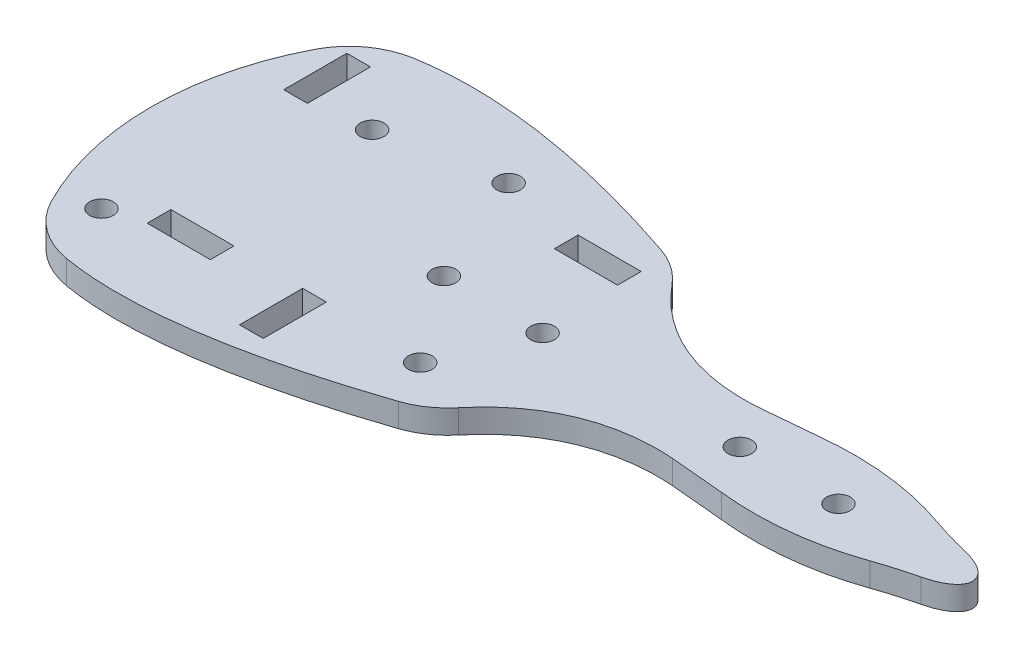
from build123d import *

# Parameters (mm, degrees)
ESBO_O1_R                = 1.5
ESBO_O1_W                = 3
ESBO_O1_H                = 8
ESBO_O1_W_2              = 8
ESBO_O1_H_2              = 3
RESSALTO_EXTRUS_O1_DEPTH = 3


with BuildPart() as part:
    # Esboço1 → Ressalto-extrusão1 (new body)
    with BuildSketch(Plane(origin=(0, 0, 0), x_dir=(1, 0, 0), z_dir=(0, 1, 0))):
        with BuildLine():
            Line((-4.674449837, 5.126823449), (2.15649844, 5.74992269))
            add(Edge.make_bspline(
                [(19.127700004, 3.859391667), (13.692888976, 5.757269931), (8.035822873, 6.387450044), (2.15649844, 5.74992269)],
                knots=[0.35388944, 0.35388944, 0.35388944, 0.35388944, 1, 1, 1, 1], degree=3))
            ThreePointArc((19.127700004, 3.859391667), (21.595587829, 3.06871935), (24.101127023, 2.406974398))
            add(Edge.make_bspline(
                [(24.101129521, -3.20712694), (35.966754752, -0.40007519), (24.101127023, 2.406974398)],
                knots=[5.194112275, 5.194112275, 5.194112275, 7.372258742, 7.372258742, 7.372258742], degree=2, weights=[1, 0.463306864, 1]))
            ThreePointArc((24.101129521, -3.20712694), (21.595589041, -3.868872862), (19.127700004, -4.659546287))
            add(Edge.make_bspline(
                [(19.127700004, -4.659546287), (13.692889505, -6.55742607), (8.035822337, -7.187603127), (2.15649844, -6.55007731)],
                knots=[0.35388944, 0.35388944, 0.35388944, 0.35388944, 1, 1, 1, 1], degree=3))
            Line((2.15649844, -6.55007731), (-4.674449837, -5.926978069))
            add(Edge.make_bspline(
                [(-23.759026807, -13.92609603), (-18.993134449, -8.145749128), (-12.424143506, -5.367564321), (-4.674449837, -5.926978069)],
                knots=[0.101821695, 0.101821695, 0.101821695, 0.101821695, 1, 1, 1, 1], degree=3))
            ThreePointArc((-23.759026807, -13.92609603), (-25.800414194, -15.798822034), (-28.277263571, -17.039621097))
            add(Edge.make_bspline(
                [(-28.277263571, -17.039621097), (-34.579205058, -19.166234), (-47.597806191, -22.747709276), (-59.650258973, -23.294853785), (-64.986052109, -22.387135922)],
                knots=[0.241589655, 0.241589655, 0.241589655, 0.241589655, 0.401358205, 0.561126756, 0.561126756, 0.561126756, 0.561126756], degree=3))
            ThreePointArc((-64.986052109, -22.387135922), (-69.209775007, -20.602207926), (-72.192804257, -17.119774932))
            ThreePointArc((-72.192804257, -17.119774932), (-76.257665323, -0.40007754), (-72.192804468, 16.319619904))
            ThreePointArc((-72.192804468, 16.319619904), (-69.209774999, 19.802053128), (-64.986051746, 21.586981094))
            add(Edge.make_bspline(
                [(-28.2772637, 16.239466453), (-34.57920511, 18.366079177), (-47.597806077, 21.947554059), (-59.650258689, 22.494698656), (-64.986051746, 21.586981094)],
                knots=[0.241589656, 0.241589656, 0.241589656, 0.241589656, 0.401358204, 0.561126752, 0.561126752, 0.561126752, 0.561126752], degree=3))
            ThreePointArc((-28.2772637, 16.239466453), (-25.80041422, 14.998667392), (-23.759026751, 13.125941342))
            add(Edge.make_bspline(
                [(-23.759026751, 13.125941342), (-18.993134399, 7.345594488), (-12.424143468, 4.567409699), (-4.674449837, 5.126823449)],
                knots=[0.101821698, 0.101821698, 0.101821698, 0.101821698, 1, 1, 1, 1], degree=3))
        make_face()
        with Locations((-45.242023738, 13.89992269)):
            Circle(ESBO_O1_R, mode=Mode.SUBTRACT)
        with Locations((-68.242023738, -14.70007731)):
            Circle(ESBO_O1_R, mode=Mode.SUBTRACT)
        with Locations((-59.742023738, 11.09992269)):
            Circle(ESBO_O1_R, mode=Mode.SUBTRACT)
        with Locations((-31.142023738, -11.40175485)):
            Circle(ESBO_O1_R, mode=Mode.SUBTRACT)
        with Locations((-39.142023738, -0.40007731)):
            Circle(ESBO_O1_R, mode=Mode.SUBTRACT)
        with Locations((10.857976262, -0.40007731)):
            Circle(ESBO_O1_R, mode=Mode.SUBTRACT)
        with Locations((-1.642023738, -0.40007731)):
            Circle(ESBO_O1_R, mode=Mode.SUBTRACT)
        with Locations((-26.642023738, -0.40007731)):
            Circle(ESBO_O1_R, mode=Mode.SUBTRACT)
        with Locations((-45.242023738, -14.70007731)):
            Rectangle(ESBO_O1_W, ESBO_O1_H, mode=Mode.SUBTRACT)
        with Locations((-68.242023738, 13.89992269)):
            Rectangle(ESBO_O1_W, ESBO_O1_H, mode=Mode.SUBTRACT)
        with Locations((-31.142023738, 11.099922699)):
            Rectangle(ESBO_O1_W_2, ESBO_O1_H_2, mode=Mode.SUBTRACT)
        with Locations((-59.742023738, -11.90007731)):
            Rectangle(ESBO_O1_W_2, ESBO_O1_H_2, mode=Mode.SUBTRACT)
    extrude(amount=RESSALTO_EXTRUS_O1_DEPTH)


solid = part.part
